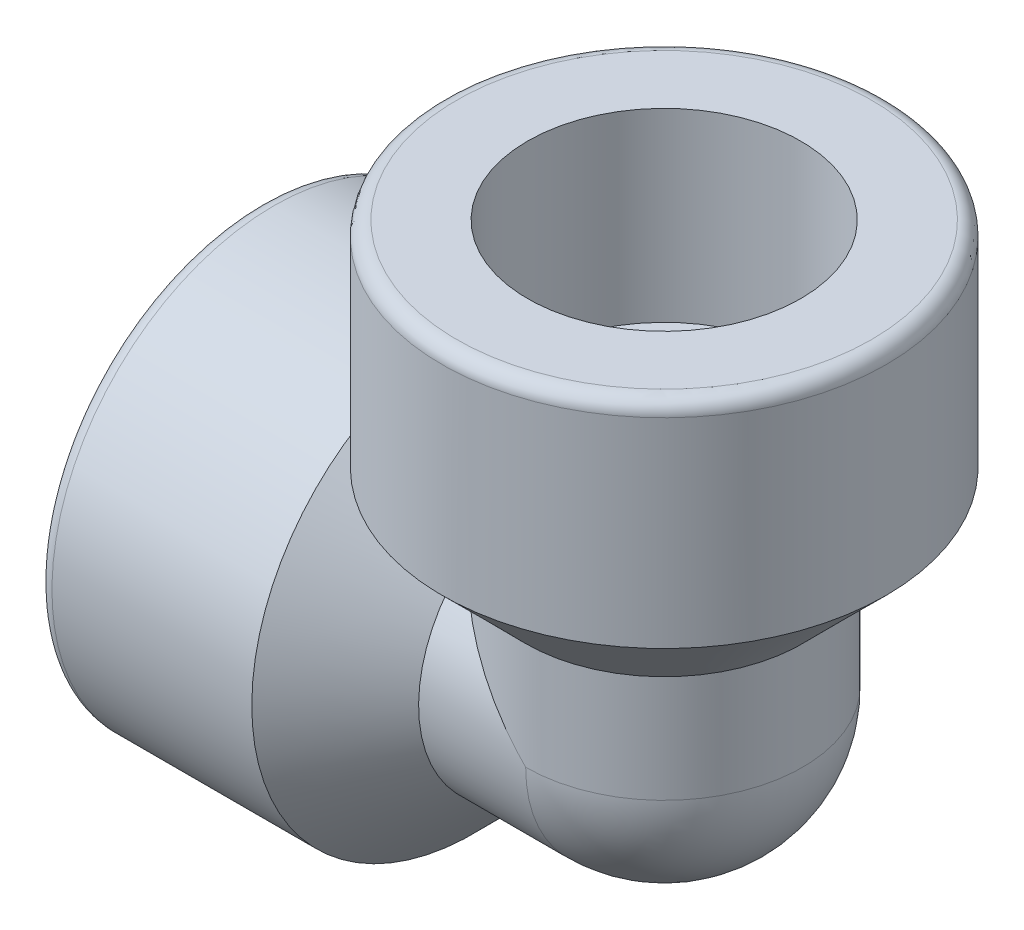
from build123d import *

# Parameters (mm, degrees)
CIRPATTERN2_COUNT  = 2
CIRPATTERN2_ANGLE  = 90
SKETCH4_R          = 4.191
CUT_EXTRUDE1_DEPTH = 22.082
SKETCH5_R          = 4.191
CUT_EXTRUDE2_DEPTH = 22.082
REVOLVE2_ANGLE     = 90


with BuildPart() as part:
    # Sketch2 → Revolve1 (revolve)
    with BuildSketch(Plane.XY):
        with BuildLine():
            Line((-21.082, -7.112), (-11.43, -7.112))
            Line((-11.43, -7.112), (-11.43, -4.191))
            Line((-11.43, -4.191), (0, -4.191))
            Line((0, -4.191), (0, -7.2136))
            Line((0, -7.2136), (-5.5753, -7.2136))
            Line((-5.5753, -7.2136), (-9.9187, -11.557))
            Line((-9.9187, -11.557), (-20.32635, -11.557))
            ThreePointArc((-20.32635, -11.557), (-20.860675239, -11.335675239), (-21.082, -10.80135))
            Line((-21.082, -10.80135), (-21.082, -7.112))
        make_face()
    revolve(axis=Axis((0, 0, 0), (-1, 0, 0)))


with BuildPart() as cirpattern2_1:
    # CirPattern2: pattern copy
    add(part.part.rotate(Axis((0, 0, -11.557), (0, 0, -1)), 1 * CIRPATTERN2_ANGLE / (CIRPATTERN2_COUNT - 1)))

    # Sketch4 → Cut-Extrude1 (cut, through all)
    with BuildSketch(Plane(origin=(0, 0, 0), x_dir=(0, 0, -1), z_dir=(1, 0, 0))):
        Circle(SKETCH4_R)
    extrude(amount=-CUT_EXTRUDE1_DEPTH, mode=Mode.SUBTRACT)


with BuildPart() as part_1:
    add(part.part)

    # Sketch5 → Cut-Extrude2 (cut, through all)
    with BuildSketch(Plane.XZ):
        Circle(SKETCH5_R)
    extrude(amount=-CUT_EXTRUDE2_DEPTH, mode=Mode.SUBTRACT)

    # Combine1: union CirPattern2_1
    add(cirpattern2_1.part)

    # Sketch6 → Revolve2 (revolve)
    with BuildSketch(Plane(origin=(0, 0, 0), x_dir=(0, 0, -1), z_dir=(1, 0, 0))):
        with BuildLine():
            Line((-7.2136, 0), (-4.191, 0))
            ThreePointArc((-4.191, 0), (0, -4.191), (4.191, 0))
            Line((4.191, 0), (7.2136, 0))
            ThreePointArc((7.2136, 0), (0, -7.2136), (-7.2136, 0))
        make_face()
    revolve(axis=Axis((0, 0, 4.191), (0, 0, 1)), revolution_arc=REVOLVE2_ANGLE)


solid = part_1.part
